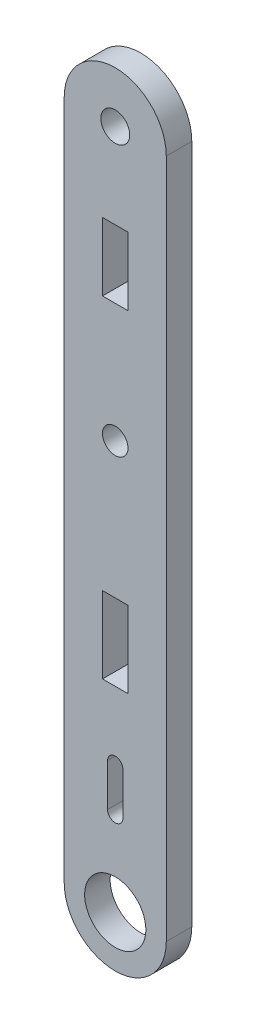
from build123d import *

# Parameters (mm, degrees)
MODEL_R             = 3.6
MODEL_R_2           = 1.7
MODEL_R_3           = 1.500000002
MODEL_W             = 3
MODEL_H             = 9
MODEL_H_2           = 8
BOSS_EXTRUDE1_DEPTH = 3


with BuildPart() as part:
    # Model → Boss-Extrude1 (new body)
    with BuildSketch(Plane.XY):
        with BuildLine():
            Line((39.51904, 20.352307471), (39.51904, 75.773102336))
            Line((39.51904, 75.773102336), (39.51904, 86.677548788))
            ThreePointArc((39.51904, 86.677548788), (33.51909, 92.677598788), (27.51904, 86.677648789))
            Line((27.51904, 86.677648789), (27.51904, 6.677548789))
            ThreePointArc((27.51904, 6.677548789), (33.519039999, 0.677548789), (39.51904, 6.677548789))
            Line((39.51904, 6.677548789), (39.51904, 20.352307471))
        make_face()
        with Locations((33.519039999, 6.677548788)):
            Circle(MODEL_R, mode=Mode.SUBTRACT)
        with Locations((33.519039998, 86.677548787)):
            Circle(MODEL_R_2, mode=Mode.SUBTRACT)
        with Locations((33.519040002, 54.677648787)):
            Circle(MODEL_R_3, mode=Mode.SUBTRACT)
        with Locations((33.51904, 34.177548789)):
            Rectangle(MODEL_W, MODEL_H, mode=Mode.SUBTRACT)
        with Locations((33.51904, 72.677548789)):
            Rectangle(MODEL_W, MODEL_H_2, mode=Mode.SUBTRACT)
        with BuildLine():
            Line((32.61904, 21.677648789), (32.61904, 16.677548789))
            ThreePointArc((32.61904, 16.677548789), (33.51904, 15.777548789), (34.41904, 16.677548789))
            Line((34.41904, 16.677548789), (34.41904, 21.677548786))
            ThreePointArc((34.41904, 21.677548786), (33.519090001, 22.577598787), (32.61904, 21.677648789))
        make_face(mode=Mode.SUBTRACT)
    extrude(amount=BOSS_EXTRUDE1_DEPTH)


solid = part.part
